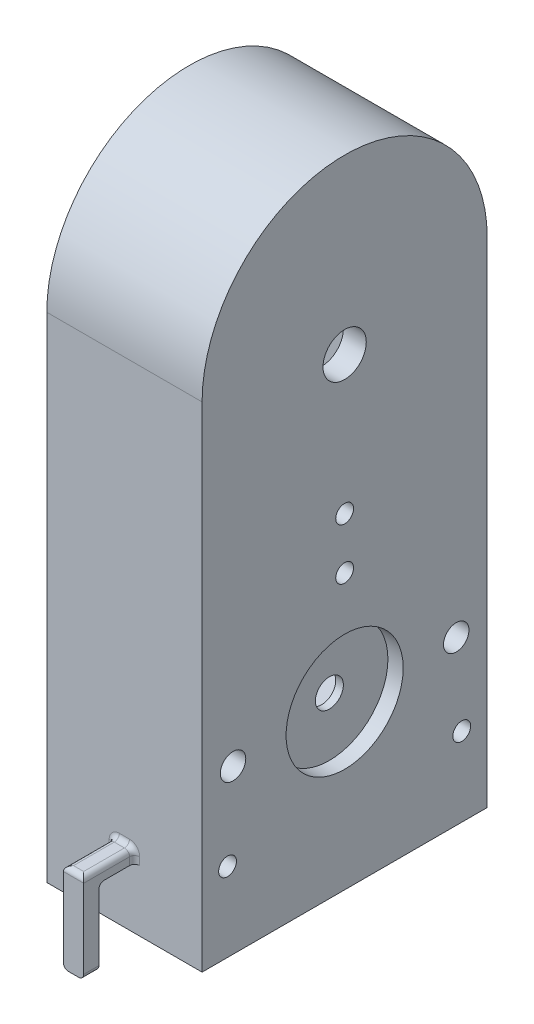
from build123d import *

# Parameters (mm, degrees)
SKETCH2_W           = 30.5
SKETCH2_H           = 56
BOSS_EXTRUDE3_DEPTH = 85
BOSS_EXTRUDE4_DEPTH = 30.5
CUT_EXTRUDE2_DEPTH  = 26
SKETCH5_R           = 2.75
SKETCH5_R_2         = 4.25
SKETCH5_R_3         = 1.75
CUT_EXTRUDE3_DEPTH  = 10
SKETCH7_R           = 11.5
CUT_EXTRUDE5_DEPTH  = 3
SKETCH9_R           = 1.75
CUT_EXTRUDE7_DEPTH  = 77
SKETCH6_R           = 2.5
SKETCH6_R_2         = 1.75
CUT_EXTRUDE8_DEPTH  = 77
BOSS_EXTRUDE5_DEPTH = 10
SKETCH12_W          = 4
SKETCH12_H          = 3
BOSS_EXTRUDE6_DEPTH = 15
FILLET2_R           = 1
SKETCH13_W          = 30.5
SKETCH13_H          = 56
BOSS_EXTRUDE7_DEPTH = 12
CUT_EXTRUDE9_DEPTH  = 22


with BuildPart() as part:
    # Sketch2 → Boss-Extrude3 (new body)
    with BuildSketch(Plane(origin=(0, 0, 0), x_dir=(1, 0, 0), z_dir=(0, 1, 0))):
        with Locations((15.25, -28)):
            Rectangle(SKETCH2_W, SKETCH2_H)
    extrude(amount=BOSS_EXTRUDE3_DEPTH)

    # Sketch4 → Boss-Extrude4 (add)
    with BuildSketch(Plane(origin=(30.5, 0, 0), x_dir=(0, 0, -1), z_dir=(1, 0, 0))):
        with BuildLine():
            Line((-56, 85), (0, 85))
            ThreePointArc((0, 85), (-28, 113), (-56, 85))
        make_face()
    extrude(amount=-BOSS_EXTRUDE4_DEPTH)

    # Sketch3 → Cut-Extrude2 (cut)
    with BuildSketch(Plane.ZY):
        with BuildLine():
            Line((5, 10), (5, 80))
            Line((5, 80), (5, 85))
            ThreePointArc((5, 85), (28, 108), (51, 85))
            Line((51, 85), (51, 80))
            Line((51, 80), (51, 10))
            Line((51, 10), (51, 7))
            Line((51, 7), (5, 7))
            Line((5, 7), (5, 10))
        make_face()
    extrude(amount=-CUT_EXTRUDE2_DEPTH, mode=Mode.SUBTRACT)

    # Sketch5 → Cut-Extrude3 (cut)
    with BuildSketch(Plane.ZY.offset(-26)):
        with Locations((28, 20)):
            Circle(SKETCH5_R)
        with Locations((28, 79.06)):
            Circle(SKETCH5_R_2)
        with Locations((28, 52)):
            Circle(SKETCH5_R_3)
    extrude(amount=-CUT_EXTRUDE3_DEPTH, mode=Mode.SUBTRACT)

    # Sketch7 → Cut-Extrude5 (cut)
    with BuildSketch(Plane(origin=(30.5, 0, 0), x_dir=(0, 0, -1), z_dir=(1, 0, 0))):
        with Locations((-28, 20)):
            Circle(SKETCH7_R)
    extrude(amount=-CUT_EXTRUDE5_DEPTH, mode=Mode.SUBTRACT)

    # Sketch9 → Cut-Extrude7 (cut)
    with BuildSketch(Plane.ZY):
        with Locations((5, 3.5)):
            Circle(SKETCH9_R)
        with Locations((51, 3.5)):
            Circle(SKETCH9_R)
    extrude(amount=-CUT_EXTRUDE7_DEPTH, mode=Mode.SUBTRACT)

    # Sketch6 → Cut-Extrude8 (cut)
    with BuildSketch(Plane(origin=(30.5, 0, 0), x_dir=(0, 0, -1), z_dir=(1, 0, 0))):
        with Locations((-49.92, 20)):
            Circle(SKETCH6_R)
        with Locations((-6.08, 20)):
            Circle(SKETCH6_R)
        with Locations((-28, 41.92)):
            Circle(SKETCH6_R_2)
    extrude(amount=-CUT_EXTRUDE8_DEPTH, mode=Mode.SUBTRACT)

    # Sketch11 → Boss-Extrude5 (add)
    with BuildSketch(Plane.XY.offset(56)):
        Polygon((15.25, 2.5), (17.25, 2.5), (17.25, 0), (15.25, 0), (13.25, 0), (13.25, 2.5), align=None)
    extrude(amount=BOSS_EXTRUDE5_DEPTH)

    # Sketch12 → Boss-Extrude6 (add)
    with BuildSketch(Plane.XZ):
        with Locations((15.25, 64.5)):
            Rectangle(SKETCH12_W, SKETCH12_H)
    extrude(amount=BOSS_EXTRUDE6_DEPTH)

    # Fillet2
    fillet2_edges = [part.edges().sort_by_distance(p)[0] for p in [
        (17.25, 1.25, 56),
        (15.25, 2.5, 56),
        (17.25, 2.5, 61),
        (13.25, 1.25, 56),
        (13.25, 2.5, 61),
        (15.25, 2.5, 66),
        (15.25, 0, 63),
        (13.25, -15, 64.5),
        (17.25, -15, 64.5),
    ]]
    fillet(fillet2_edges, radius=FILLET2_R)

    # Sketch13 → Boss-Extrude7 (add)
    with BuildSketch(Plane.XZ):
        with Locations((15.25, 28)):
            Rectangle(SKETCH13_W, SKETCH13_H)
        with BuildLine():
            Line((8.34810103, 28.004718314), (12.411901595, 23.940917749))
            Line((12.411901595, 23.940917749), (16.65189897, 28.180915124))
            Line((16.65189897, 28.180915124), (12.592816719, 32.239997375))
            ThreePointArc((12.592816719, 32.239997375), (9.593303861, 31.001467248), (8.34810103, 28.004718314))
        make_face(mode=Mode.SUBTRACT)
    extrude(amount=BOSS_EXTRUDE7_DEPTH)

    # Sketch15 → Cut-Extrude9 (cut)
    with BuildSketch(Plane.XZ.offset(12)):
        with BuildLine():
            Line((8.34810103, 28.004718314), (12.411901595, 23.940917749))
            Line((12.411901595, 23.940917749), (16.65189897, 28.180915124))
            Line((16.65189897, 28.180915124), (12.592816719, 32.239997375))
            ThreePointArc((12.592816719, 32.239997375), (9.593303861, 31.001467248), (8.34810103, 28.004718314))
        make_face()
    extrude(amount=-CUT_EXTRUDE9_DEPTH, mode=Mode.SUBTRACT)


solid = part.part
